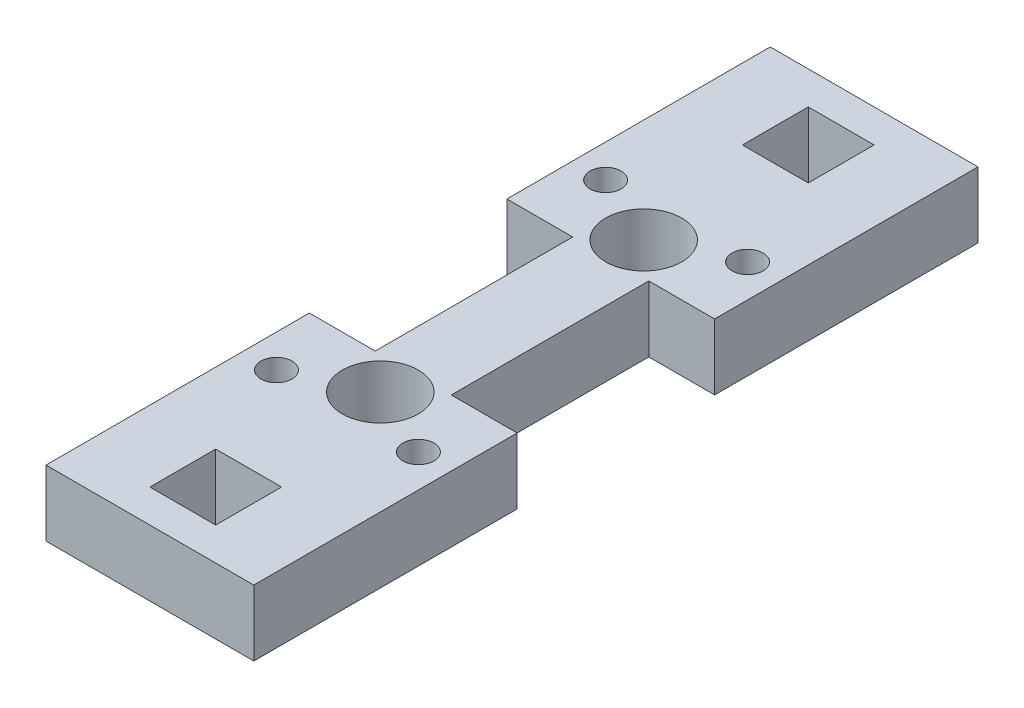
from build123d import *

# Parameters (mm, degrees)
SKETCH1_W           = 6.35
SKETCH1_H           = 6.35
SKETCH1_R           = 3.6703
BOSS_EXTRUDE1_DEPTH = 6.35
SKETCH2_R           = 1.5
CUT_EXTRUDE1_DEPTH  = 7.35


with BuildPart() as part:
    # Sketch1 → Boss-Extrude1 (new body)
    with BuildSketch(Plane(origin=(0, 0, 0), x_dir=(1, 0, 0), z_dir=(0, 1, 0))):
        Polygon((0, 25.4), (0, 0), (20.0406, 0), (20.0406, 25.4), (13.6906, 25.4), (13.6906, 44.45), (20.0406, 44.45), (20.0406, 69.85), (0, 69.85), (0, 44.45), (6.35, 44.45), (6.35, 25.4), align=None)
        with Locations((10.0203, 6.35)):
            Rectangle(SKETCH1_W, SKETCH1_H, mode=Mode.SUBTRACT)
        with Locations((10.0203, 22.225)):
            Circle(SKETCH1_R, mode=Mode.SUBTRACT)
        with Locations((10.0203, 63.5)):
            Rectangle(SKETCH1_W, SKETCH1_H, mode=Mode.SUBTRACT)
        with Locations((10.0203, 47.625)):
            Circle(SKETCH1_R, mode=Mode.SUBTRACT)
    extrude(amount=BOSS_EXTRUDE1_DEPTH)

    # Sketch2 → Cut-Extrude1 (cut, through all)
    with BuildSketch(Plane(origin=(0, 6.35, 0), x_dir=(1, 0, 0), z_dir=(0, 1, 0))):
        with Locations((3.175, 50.8)):
            Circle(SKETCH2_R)
        with Locations((3.175, 19.05)):
            Circle(SKETCH2_R)
        with Locations((16.8656, 19.05)):
            Circle(SKETCH2_R)
        with Locations((16.8656, 50.8)):
            Circle(SKETCH2_R)
    extrude(amount=-CUT_EXTRUDE1_DEPTH, mode=Mode.SUBTRACT)


solid = part.part
